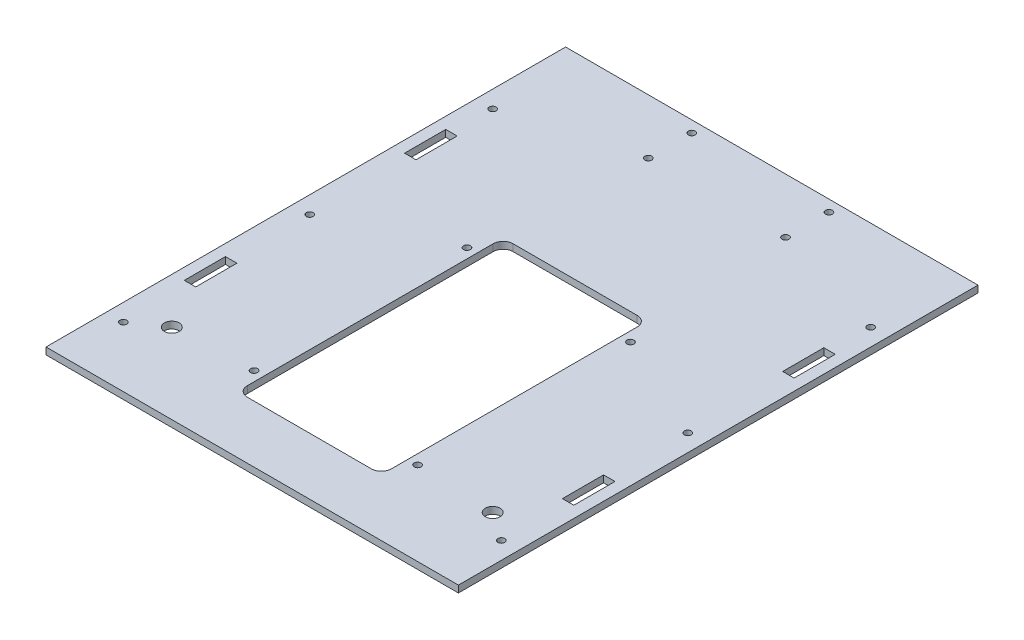
from build123d import *

# Parameters (mm, degrees)
SCHIZZO1_W                   = 180.34
SCHIZZO1_H                   = 227.22
ESTRUSIONE_ESTRUSIONE1_DEPTH = 3
SCHIZZO2_R                   = 1.5
SCHIZZO2_R_2                 = 3.25
SCHIZZO2_W                   = 5
SCHIZZO2_H                   = 18
TAGLIO_ESTRUSIONE1_DEPTH     = 4
SCHIZZO3_R                   = 1.5
TAGLIO_ESTRUSIONE5_DEPTH     = 4


with BuildPart() as part:
    # Schizzo1 → Estrusione-Estrusione1 (new body)
    with BuildSketch(Plane(origin=(0, 0, 0), x_dir=(1, 0, 0), z_dir=(0, 1, 0))):
        Rectangle(SCHIZZO1_W, SCHIZZO1_H)
    extrude(amount=ESTRUSIONE_ESTRUSIONE1_DEPTH)

    # Schizzo2 → Taglio-Estrusione1 (cut, through all)
    with BuildSketch(Plane(origin=(0, 0, 0), x_dir=(1, 0, 0), z_dir=(0, 1, 0))):
        with Locations((-82.67, -5.81)):
            Circle(SCHIZZO2_R)
        with Locations((-82.67, -87.31)):
            Circle(SCHIZZO2_R)
        with Locations((-82.67, 74.19)):
            Circle(SCHIZZO2_R)
        with Locations((82.67, -87.31)):
            Circle(SCHIZZO2_R)
        with Locations((82.67, -5.81)):
            Circle(SCHIZZO2_R)
        with Locations((82.67, 74.19)):
            Circle(SCHIZZO2_R)
        with Locations((-70.17, -78.61)):
            Circle(SCHIZZO2_R_2)
        with Locations((70.17, -78.61)):
            Circle(SCHIZZO2_R_2)
        with Locations((-30, 89.61)):
            Circle(SCHIZZO2_R)
        with Locations((-30, 108.61)):
            Circle(SCHIZZO2_R)
        with Locations((30, 89.61)):
            Circle(SCHIZZO2_R)
        with Locations((30, 108.61)):
            Circle(SCHIZZO2_R)
        with Locations((82.67, -49.13)):
            Rectangle(SCHIZZO2_W, SCHIZZO2_H)
        with Locations((-82.67, -49.13)):
            Rectangle(SCHIZZO2_W, SCHIZZO2_H)
        with Locations((-82.67, 47.19)):
            Rectangle(SCHIZZO2_W, SCHIZZO2_H)
        with Locations((82.67, 47.19)):
            Rectangle(SCHIZZO2_W, SCHIZZO2_H)
    extrude(amount=TAGLIO_ESTRUSIONE1_DEPTH, mode=Mode.SUBTRACT)

    # Schizzo3 → Taglio-Estrusione5 (cut, through all)
    with BuildSketch(Plane(origin=(0, 0, 0), x_dir=(1, 0, 0), z_dir=(0, 1, 0))):
        with Locations((-35.75, -77.045)):
            Circle(SCHIZZO3_R)
        with Locations((35.75, -77.045)):
            Circle(SCHIZZO3_R)
        with Locations((-35.75, 16.055)):
            Circle(SCHIZZO3_R)
        with Locations((35.75, 16.055)):
            Circle(SCHIZZO3_R)
        with BuildLine():
            Line((-31.5, -84.26), (-31.5, 23.27))
            ThreePointArc((-31.5, 23.27), (-30.225914498, 26.345914498), (-27.15, 27.62))
            Line((-27.15, 27.62), (27.15, 27.62))
            ThreePointArc((27.15, 27.62), (30.225914498, 26.345914498), (31.5, 23.27))
            Line((31.5, 23.27), (31.5, -84.26))
            ThreePointArc((31.5, -84.26), (30.225914498, -87.335914498), (27.15, -88.61))
            Line((27.15, -88.61), (-27.15, -88.61))
            ThreePointArc((-27.15, -88.61), (-30.225914498, -87.335914498), (-31.5, -84.26))
        make_face()
    extrude(amount=TAGLIO_ESTRUSIONE5_DEPTH, mode=Mode.SUBTRACT)


solid = part.part
